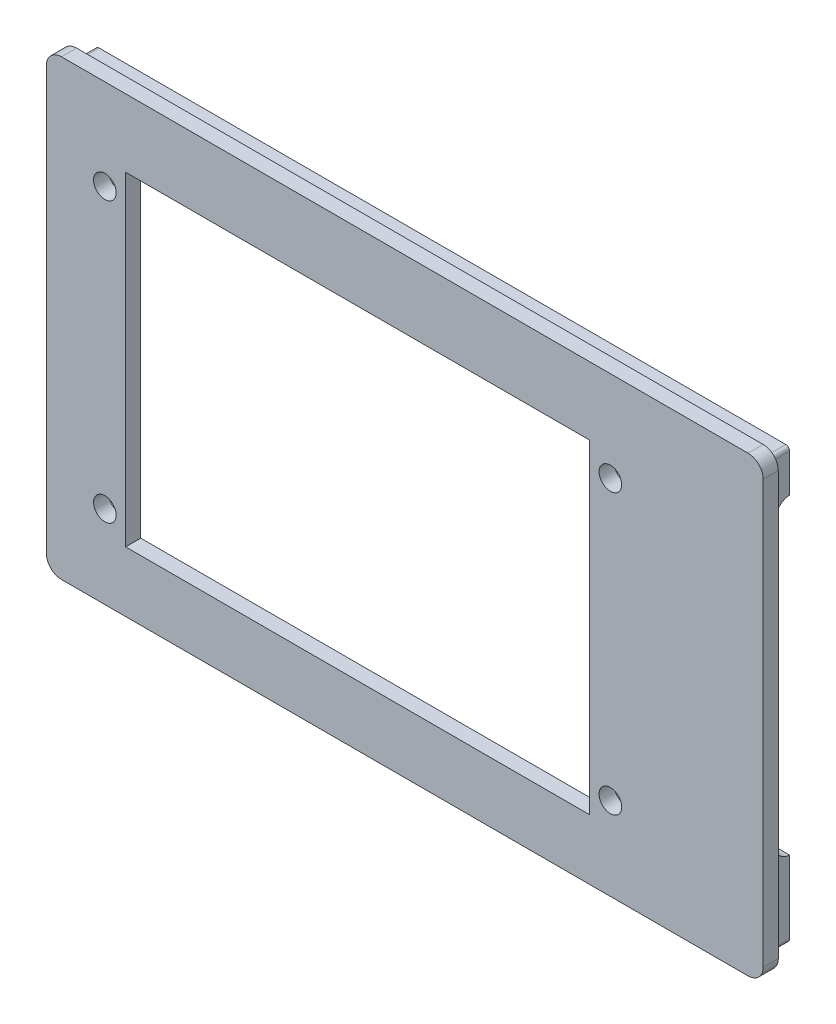
from build123d import *

# Parameters (mm, degrees)
SKETCH1_W           = 61.5
SKETCH1_H           = 43
BOSS_EXTRUDE1_DEPTH = 2
SKETCH2_W           = 89
SKETCH2_H           = 54
BOSS_EXTRUDE2_DEPTH = 3
CUT_EXTRUDE1_REACH  = 114.472
SKETCH3_R           = 1.5
CUT_EXTRUDE2_REACH  = 113.136


with BuildPart() as part:
    # Sketch1 → Boss-Extrude1 (new body)
    with BuildSketch(Plane.XY):
        with BuildLine():
            Line((2, 0), (93, 0))
            ThreePointArc((93, 0), (94.414213562, 0.585786438), (95, 2))
            Line((95, 2), (95, 58))
            ThreePointArc((95, 58), (94.414213562, 59.414213562), (93, 60))
            Line((93, 60), (2, 60))
            ThreePointArc((2, 60), (0.585786438, 59.414213562), (0, 58))
            Line((0, 58), (0, 2))
            ThreePointArc((0, 2), (0.585786438, 0.585786438), (2, 0))
        make_face()
        with Locations((41.25, 29.5)):
            Rectangle(SKETCH1_W, SKETCH1_H, mode=Mode.SUBTRACT)
    extrude(amount=BOSS_EXTRUDE1_DEPTH)

    # Sketch2 → Boss-Extrude2 (add)
    with BuildSketch(Plane(origin=(0, 0, 0), x_dir=(-1, 0, 0), z_dir=(0, 0, -1))):
        with BuildLine():
            Line((-93.5, 58), (-93.5, 2))
            ThreePointArc((-93.5, 2), (-93.353553391, 1.646446609), (-93, 1.5))
            Line((-93, 1.5), (-2, 1.5))
            ThreePointArc((-2, 1.5), (-1.646446609, 1.646446609), (-1.5, 2))
            Line((-1.5, 2), (-1.5, 58))
            ThreePointArc((-1.5, 58), (-1.646446609, 58.353553391), (-2, 58.5))
            Line((-2, 58.5), (-93, 58.5))
            ThreePointArc((-93, 58.5), (-93.353553391, 58.353553391), (-93.5, 58))
        make_face()
        with Locations((-47.5, 30)):
            Rectangle(SKETCH2_W, SKETCH2_H, mode=Mode.SUBTRACT)
    extrude(amount=BOSS_EXTRUDE2_DEPTH)

    # Sketch3 → Cut-Extrude1 (cut, up to next)
    with BuildSketch(Plane.XY.offset(2), mode=Mode.PRIVATE) as cut_extrude1_sk1:
        with Locations((7.75, 48)):
            Circle(SKETCH3_R)
    cut_extrude1_tool1 = extrude(cut_extrude1_sk1.sketch, amount=-CUT_EXTRUDE1_REACH, mode=Mode.PRIVATE) & part.part
    # Sketch3 → Cut-Extrude1 (cut, up to next)
    with BuildSketch(Plane.XY.offset(2), mode=Mode.PRIVATE) as cut_extrude1_sk2:
        with Locations((74.75, 48)):
            Circle(SKETCH3_R)
    cut_extrude1_tool2 = extrude(cut_extrude1_sk2.sketch, amount=-CUT_EXTRUDE1_REACH, mode=Mode.PRIVATE) & part.part
    # Sketch3 → Cut-Extrude1 (cut, up to next)
    with BuildSketch(Plane.XY.offset(2), mode=Mode.PRIVATE) as cut_extrude1_sk3:
        with Locations((7.75, 11)):
            Circle(SKETCH3_R)
    cut_extrude1_tool3 = extrude(cut_extrude1_sk3.sketch, amount=-CUT_EXTRUDE1_REACH, mode=Mode.PRIVATE) & part.part
    # Sketch3 → Cut-Extrude1 (cut, up to next)
    with BuildSketch(Plane.XY.offset(2), mode=Mode.PRIVATE) as cut_extrude1_sk4:
        with Locations((74.75, 11)):
            Circle(SKETCH3_R)
    cut_extrude1_tool4 = extrude(cut_extrude1_sk4.sketch, amount=-CUT_EXTRUDE1_REACH, mode=Mode.PRIVATE) & part.part
    add(cut_extrude1_tool1.solids().sort_by_distance((7.75, 48, 2))[0], mode=Mode.SUBTRACT)
    add(cut_extrude1_tool2.solids().sort_by_distance((74.75, 48, 2))[0], mode=Mode.SUBTRACT)
    add(cut_extrude1_tool3.solids().sort_by_distance((7.75, 11, 2))[0], mode=Mode.SUBTRACT)
    add(cut_extrude1_tool4.solids().sort_by_distance((74.75, 11, 2))[0], mode=Mode.SUBTRACT)

    # Sketch4 → Cut-Extrude2 (cut, up to next)
    with BuildSketch(Plane(origin=(93.5, 0, 0), x_dir=(0, 0, -1), z_dir=(1, 0, 0)), mode=Mode.PRIVATE) as cut_extrude2_sk1:
        with BuildLine():
            Line((6.35854024, 11.62115589), (3.091503029, 11.62115589))
            ThreePointArc((3.091503029, 11.62115589), (1.677289466, 12.206942328), (1.091503029, 13.62115589))
            Line((1.091503029, 13.62115589), (1.091503029, 50.941867475))
            ThreePointArc((1.091503029, 50.941867475), (1.677289466, 52.356081037), (3.091503029, 52.941867475))
            Line((3.091503029, 52.941867475), (6.35854024, 52.941867475))
            ThreePointArc((6.35854024, 52.941867475), (7.772753802, 52.356081037), (8.35854024, 50.941867475))
            Line((8.35854024, 50.941867475), (8.35854024, 13.62115589))
            ThreePointArc((8.35854024, 13.62115589), (7.772753802, 12.206942328), (6.35854024, 11.62115589))
        make_face()
    cut_extrude2_tool1 = extrude(cut_extrude2_sk1.sketch, amount=-CUT_EXTRUDE2_REACH, mode=Mode.PRIVATE) & part.part
    add(cut_extrude2_tool1.solids().sort_by_distance((93.5, 32.281512, -4.725022))[0], mode=Mode.SUBTRACT)


solid = part.part
